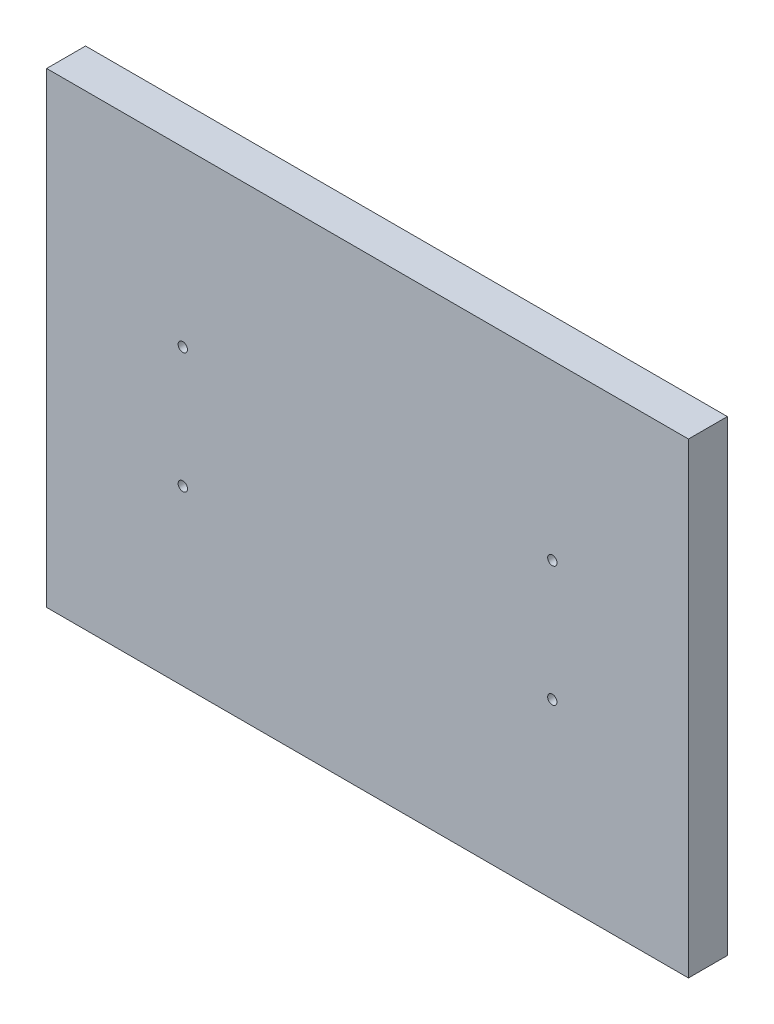
from build123d import *

# Parameters (mm, degrees)
SKETCH1_W           = 165
SKETCH1_H           = 120
SKETCH1_R           = 1.2
BOSS_EXTRUDE1_DEPTH = 10


with BuildPart() as part:
    # Sketch1 → Boss-Extrude1 (new body)
    with BuildSketch(Plane.XY):
        Rectangle(SKETCH1_W, SKETCH1_H)
        with Locations((-47.5, 15.5)):
            Circle(SKETCH1_R, mode=Mode.SUBTRACT)
        with Locations((-47.5, -15.5)):
            Circle(SKETCH1_R, mode=Mode.SUBTRACT)
        with Locations((47.5, -15.5)):
            Circle(SKETCH1_R, mode=Mode.SUBTRACT)
        with Locations((47.5, 15.5)):
            Circle(SKETCH1_R, mode=Mode.SUBTRACT)
    extrude(amount=BOSS_EXTRUDE1_DEPTH)


solid = part.part
